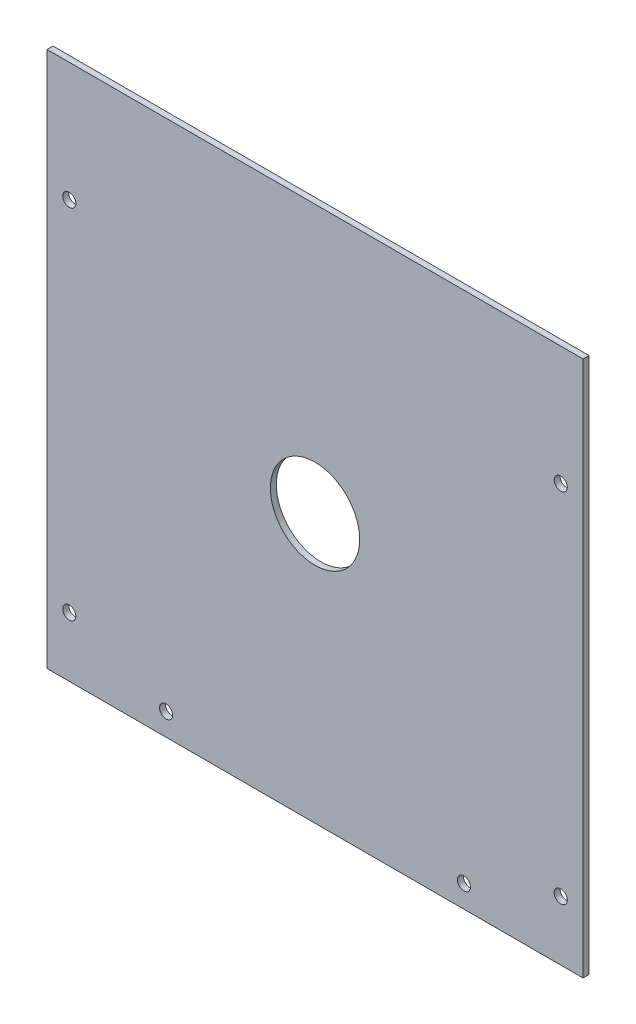
from build123d import *

# Parameters (mm, degrees)
SKETCH_1_W          = 180
SKETCH_1_H          = 180
EXTRUDE_1_DEPTH     = 2
SKETCH_2_R          = 15
CUT_EXTRUDE_1_DEPTH = 2
CUT_EXTRUDE_2_DEPTH = 3
SKETCH_4_R          = 2.2
CUT_EXTRUDE_3_DEPTH = 160


with BuildPart() as part:
    # ｽｹｯﾁ1 → ﾎﾞｽ - 押し出し1 (new body)
    with BuildSketch(Plane.XY):
        Rectangle(SKETCH_1_W, SKETCH_1_H)
    extrude(amount=EXTRUDE_1_DEPTH)

    # ｽｹｯﾁ2 → ｶｯﾄ - 押し出し1 (cut)
    with BuildSketch(Plane.XY.offset(2)):
        Circle(SKETCH_2_R)
    extrude(amount=-CUT_EXTRUDE_1_DEPTH, mode=Mode.SUBTRACT)

    # ｽｹｯﾁ3 → ｶｯﾄ - 押し出し2 (cut, through all)
    with BuildSketch(Plane(origin=(0, 0, 0), x_dir=(-1, 0, 0), z_dir=(0, 0, -1))):
        with BuildLine():
            ThreePointArc((-52.2, -82.5), (-51.555634919, -84.055634919), (-50, -84.7))
            Line((-50, -84.7), (-50, -82.5))
            Line((-50, -82.5), (-52.2, -82.5))
        make_face()
        with BuildLine():
            Line((-50, -82.5), (-50, -84.7))
            ThreePointArc((-50, -84.7), (-48.444365081, -84.055634919), (-47.8, -82.5))
            ThreePointArc((-47.8, -82.5), (-50, -80.3), (-52.2, -82.5))
            Line((-52.2, -82.5), (-50, -82.5))
        make_face()
        with BuildLine():
            ThreePointArc((52.2, -82.5), (48.444365081, -80.944365081), (50, -84.7))
            Line((50, -84.7), (50, -82.5))
            Line((50, -82.5), (52.2, -82.5))
        make_face()
        with BuildLine():
            Line((50, -82.5), (50, -84.7))
            ThreePointArc((50, -84.7), (51.555634919, -84.055634919), (52.2, -82.5))
            Line((52.2, -82.5), (50, -82.5))
        make_face()
    extrude(amount=-CUT_EXTRUDE_2_DEPTH, mode=Mode.SUBTRACT)

    # ｽｹｯﾁ4 → ｶｯﾄ - 押し出し3 (cut)
    with BuildSketch(Plane(origin=(0, 0, 0), x_dir=(-1, 0, 0), z_dir=(0, 0, -1))):
        with Locations((-82.5, -70)):
            Circle(SKETCH_4_R)
        with Locations((-82.5, 50)):
            Circle(SKETCH_4_R)
        with Locations((82.5, 50)):
            Circle(SKETCH_4_R)
        with Locations((82.5, -70)):
            Circle(SKETCH_4_R)
    extrude(amount=-CUT_EXTRUDE_3_DEPTH, mode=Mode.SUBTRACT)


solid = part.part
